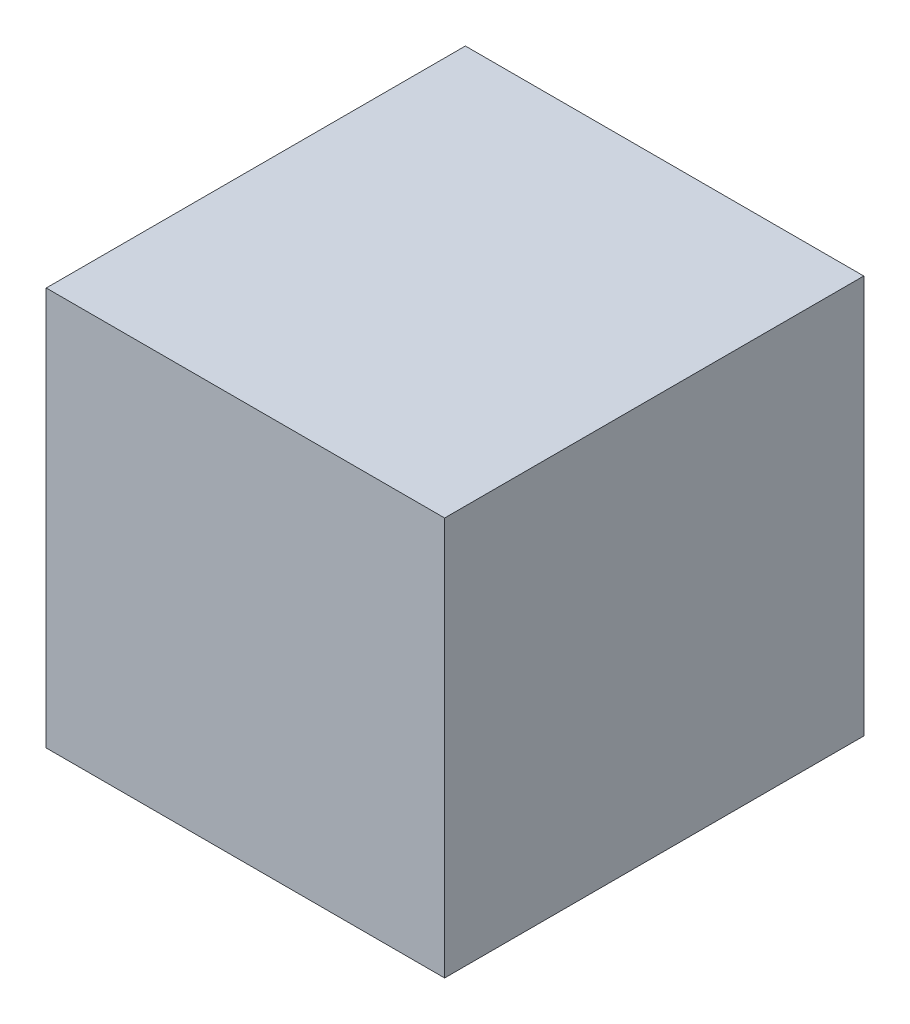
from build123d import *

# Parameters (mm, degrees)
CROQUIS2_W              = 480
CROQUIS2_H              = 505
SALIENTE_EXTRUIR1_DEPTH = 480
CROQUIS3_W              = 470
CROQUIS3_H              = 470
CORTAR_EXTRUIR1_DEPTH   = 200
CROQUIS5_W              = 450
CROQUIS5_H              = 450
CORTAR_EXTRUIR2_DEPTH   = 300
CROQUIS7_R              = 125
CORTAR_EXTRUIR3_DEPTH   = 300


with BuildPart() as part:
    # Croquis2 → Saliente-Extruir1 (new body)
    with BuildSketch(Plane(origin=(0, 0, 0), x_dir=(1, 0, 0), z_dir=(0, 1, 0))):
        Rectangle(CROQUIS2_W, CROQUIS2_H)
    extrude(amount=SALIENTE_EXTRUIR1_DEPTH)

    # Croquis3 → Cortar-Extruir1 (cut)
    with BuildSketch(Plane(origin=(0, 0, -252.5), x_dir=(-1, 0, 0), z_dir=(0, 0, -1))):
        with Locations((0, 240)):
            Rectangle(CROQUIS3_W, CROQUIS3_H)
    extrude(amount=-CORTAR_EXTRUIR1_DEPTH, mode=Mode.SUBTRACT)

    # Croquis5 → Cortar-Extruir2 (cut)
    with BuildSketch(Plane(origin=(0, 0, -52.5), x_dir=(-1, 0, 0), z_dir=(0, 0, -1))):
        with Locations((0, 240)):
            Rectangle(CROQUIS5_W, CROQUIS5_H)
    extrude(amount=-CORTAR_EXTRUIR2_DEPTH, mode=Mode.SUBTRACT)

    # Croquis7 → Cortar-Extruir3 (cut)
    with BuildSketch(Plane.ZY.offset(240)):
        with Locations((102.5, 240)):
            Circle(CROQUIS7_R)
    extrude(amount=-CORTAR_EXTRUIR3_DEPTH, mode=Mode.SUBTRACT)


solid = part.part
